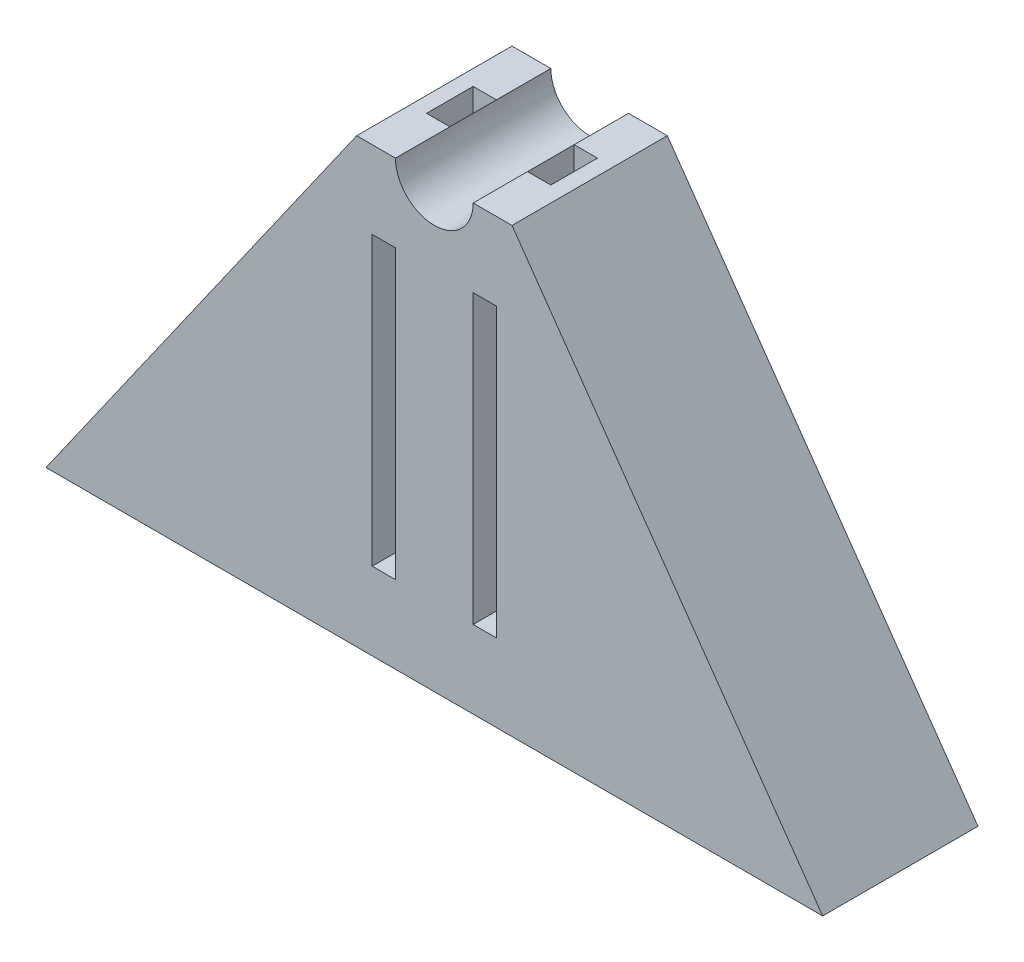
from build123d import *

# Parameters (mm, degrees)
BOSS_EXTRUDE1_DEPTH = 10
SKETCH4_W           = 1.5
SKETCH4_H           = 3
CUT_EXTRUDE2_DEPTH  = 29.5
SKETCH5_W           = 1.5
SKETCH5_H           = 18.5
CUT_EXTRUDE3_DEPTH  = 11


with BuildPart() as part:
    # Sketch1 → Boss-Extrude1 (new body)
    with BuildSketch(Plane.XY):
        with BuildLine():
            Line((-25, -28.5), (25, -28.5))
            Line((25, -28.5), (5, 0))
            Line((5, 0), (2.5, 0))
            ThreePointArc((2.5, 0), (0, -2.5), (-2.5, 0))
            Line((-2.5, 0), (-5, 0))
            Line((-5, 0), (-25, -28.5))
        make_face()
    extrude(amount=BOSS_EXTRUDE1_DEPTH)

    # Sketch4 → Cut-Extrude2 (cut, through all)
    with BuildSketch(Plane.XZ.offset(28.5)):
        with Locations((-3.25, 5)):
            Rectangle(SKETCH4_W, SKETCH4_H)
    cut_extrude2 = extrude(amount=-CUT_EXTRUDE2_DEPTH, mode=Mode.SUBTRACT)

    # Mirror1: Cut-Extrude2 across plane
    add(cut_extrude2.mirror(Plane(origin=(0, 0, 0), x_dir=(0, 0, 1), z_dir=(1, 0, 0))), mode=Mode.SUBTRACT)

    # Sketch5 → Cut-Extrude3 (cut, through all)
    with BuildSketch(Plane.XY.offset(10)):
        with Locations((-3.25, -14.25)):
            Rectangle(SKETCH5_W, SKETCH5_H)
        with Locations((3.25, -14.25)):
            Rectangle(SKETCH5_W, SKETCH5_H)
    extrude(amount=-CUT_EXTRUDE3_DEPTH, mode=Mode.SUBTRACT)


solid = part.part
